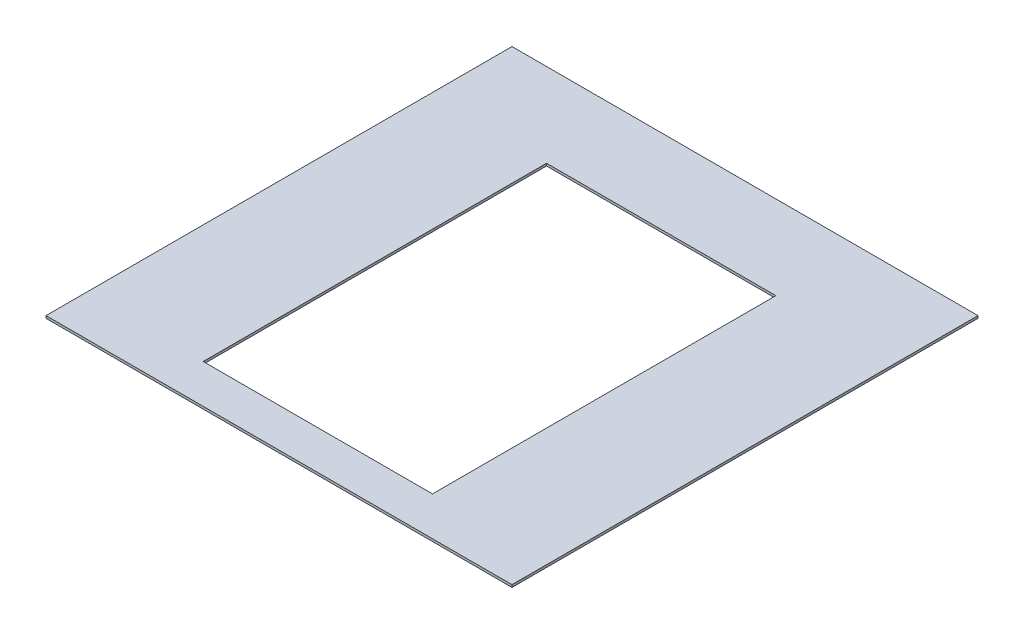
from build123d import *

# Parameters (mm, degrees)
SKETCH1_W           = 609.6
SKETCH1_H           = 609.6
SKETCH1_W_2         = 300
SKETCH1_H_2         = 449.2
BOSS_EXTRUDE1_DEPTH = 1.5875


with BuildPart() as part:
    # Sketch1 → Boss-Extrude1 (new body, symmetric)
    with BuildSketch(Plane(origin=(0, 0, 0), x_dir=(1, 0, 0), z_dir=(0, 1, 0))):
        Rectangle(SKETCH1_W, SKETCH1_H)
        with Locations((0, -29.4)):
            Rectangle(SKETCH1_W_2, SKETCH1_H_2, mode=Mode.SUBTRACT)
    extrude(amount=BOSS_EXTRUDE1_DEPTH, both=True)


solid = part.part
